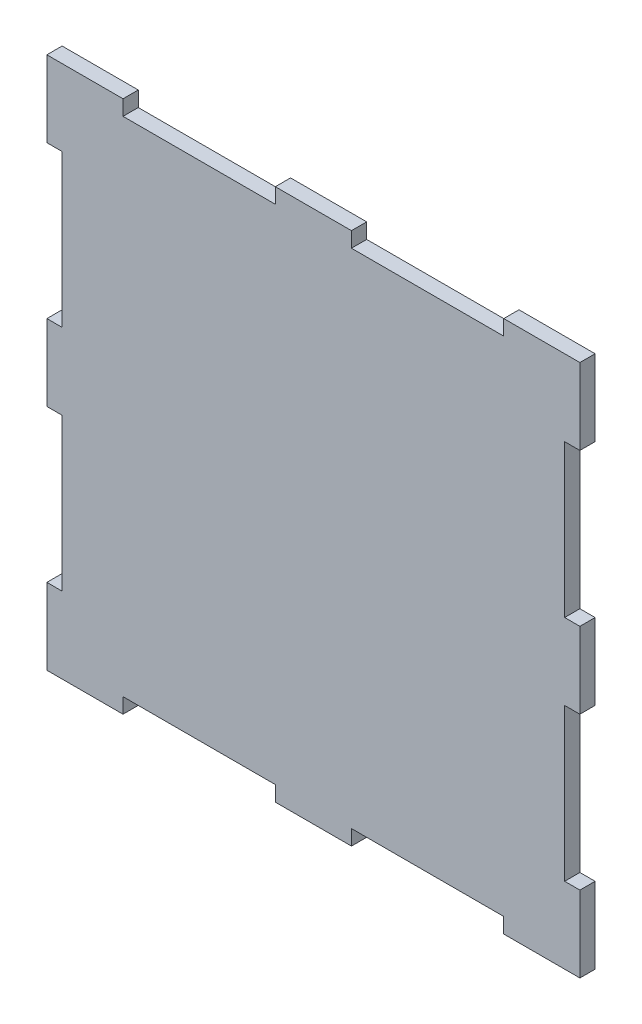
from build123d import *

# Parameters (mm, degrees)
SKETCH1_W           = 70
SKETCH1_H           = 70
BOSS_EXTRUDE1_DEPTH = 2
SKETCH2_W           = 2
SKETCH2_H           = 20
SKETCH2_W_2         = 20
SKETCH2_H_2         = 2
CUT_EXTRUDE1_DEPTH  = 2


with BuildPart() as part:
    # Sketch1 → Boss-Extrude1 (new body)
    with BuildSketch(Plane.XY):
        Rectangle(SKETCH1_W, SKETCH1_H)
    extrude(amount=-BOSS_EXTRUDE1_DEPTH)

    # Sketch2 → Cut-Extrude1 (cut)
    with BuildSketch(Plane.XY):
        with Locations((-34, 15)):
            Rectangle(SKETCH2_W, SKETCH2_H)
        with Locations((-34, -15)):
            Rectangle(SKETCH2_W, SKETCH2_H)
        with Locations((-15, -34)):
            Rectangle(SKETCH2_W_2, SKETCH2_H_2)
        with Locations((15, -34)):
            Rectangle(SKETCH2_W_2, SKETCH2_H_2)
        with Locations((34, -15)):
            Rectangle(SKETCH2_W, SKETCH2_H)
        with Locations((34, 15)):
            Rectangle(SKETCH2_W, SKETCH2_H)
        with Locations((15, 34)):
            Rectangle(SKETCH2_W_2, SKETCH2_H_2)
        with Locations((-15, 34)):
            Rectangle(SKETCH2_W_2, SKETCH2_H_2)
    extrude(amount=-CUT_EXTRUDE1_DEPTH, mode=Mode.SUBTRACT)


solid = part.part
